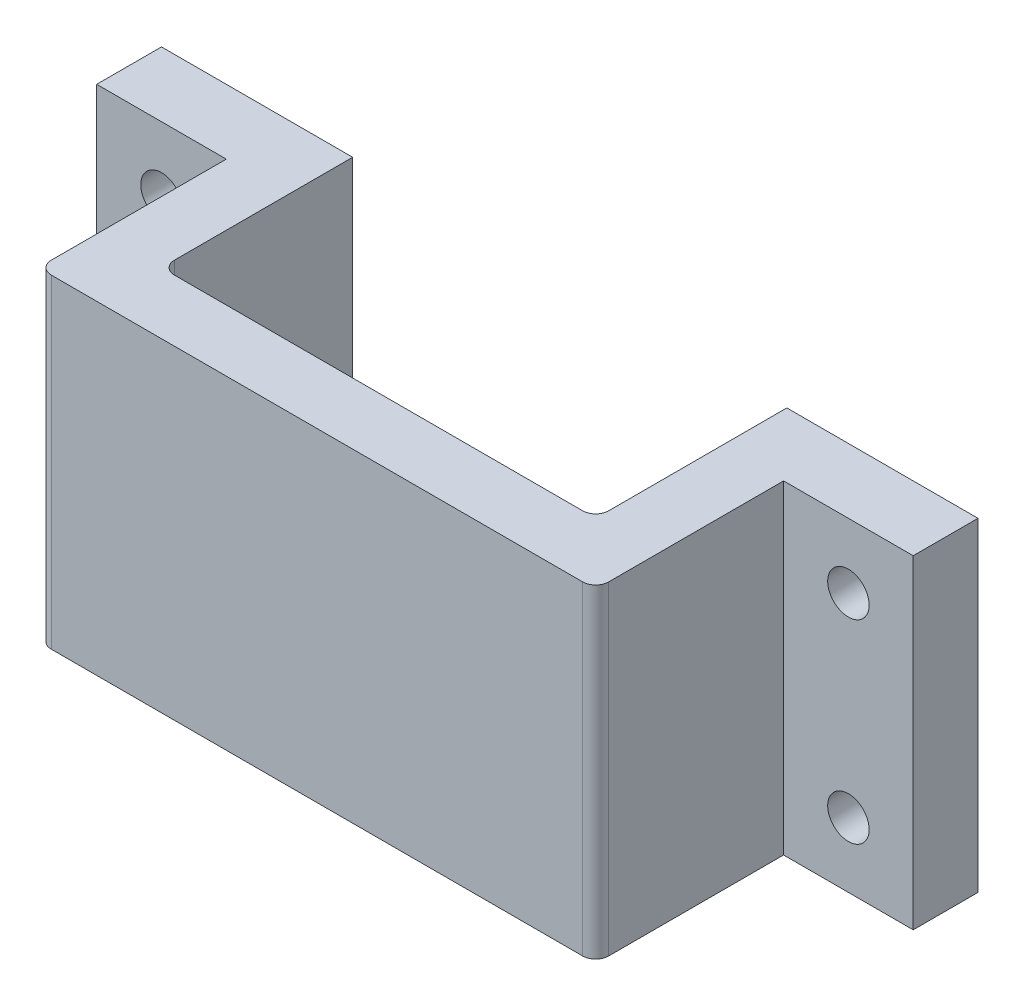
from build123d import *

# Parameters (mm, degrees)
EXTRUDE_1_DEPTH     = 25
SKETCH_2_W          = 10
SKETCH_2_H          = 25
EXTRUDE_2_DEPTH     = 5
FILLET_1_R          = 1
SKETCH_3_R          = 1.6
CUT_EXTRUDE_1_DEPTH = 20.5
FILLET_2_R          = 1


with BuildPart() as part:
    # Эскиз1 → Бобышка-Вытянуть1 (new body)
    with BuildSketch(Plane(origin=(0, 0, 0), x_dir=(1, 0, 0), z_dir=(0, 1, 0))):
        Polygon((0, 0), (43, 0), (43, 19.5), (38.25, 19.5), (38.25, 4.75), (4.75, 4.75), (4.75, 19.5), (0, 19.5), align=None)
    extrude(amount=EXTRUDE_1_DEPTH)

    # Эскиз2 → Бобышка-Вытянуть2 (add)
    with BuildSketch(Plane(origin=(0, 0, -19.5), x_dir=(-1, 0, 0), z_dir=(0, 0, -1))):
        with Locations((-48, 12.5)):
            Rectangle(SKETCH_2_W, SKETCH_2_H)
        with Locations((5, 12.5)):
            Rectangle(SKETCH_2_W, SKETCH_2_H)
    extrude(amount=-EXTRUDE_2_DEPTH)

    # Скругление1
    fillet_1_edges = [part.edges().sort_by_distance(p)[0] for p in [
        (4.75, 12.5, -4.75),
        (38.25, 12.5, -4.75),
    ]]
    fillet(fillet_1_edges, radius=FILLET_1_R)

    # Эскиз3 → Вырез-Вытянуть1 (cut, through all)
    with BuildSketch(Plane(origin=(0, 0, -19.5), x_dir=(-1, 0, 0), z_dir=(0, 0, -1))):
        with Locations((5, 20)):
            Circle(SKETCH_3_R)
        with Locations((5, 5)):
            Circle(SKETCH_3_R)
        with Locations((-48, 20)):
            Circle(SKETCH_3_R)
        with Locations((-48, 5)):
            Circle(SKETCH_3_R)
    extrude(amount=-CUT_EXTRUDE_1_DEPTH, mode=Mode.SUBTRACT)

    # Скругление2
    fillet_2_edges = [part.edges().sort_by_distance(p)[0] for p in [
        (0, 12.5, 0),
        (43, 12.5, 0),
    ]]
    fillet(fillet_2_edges, radius=FILLET_2_R)


solid = part.part
